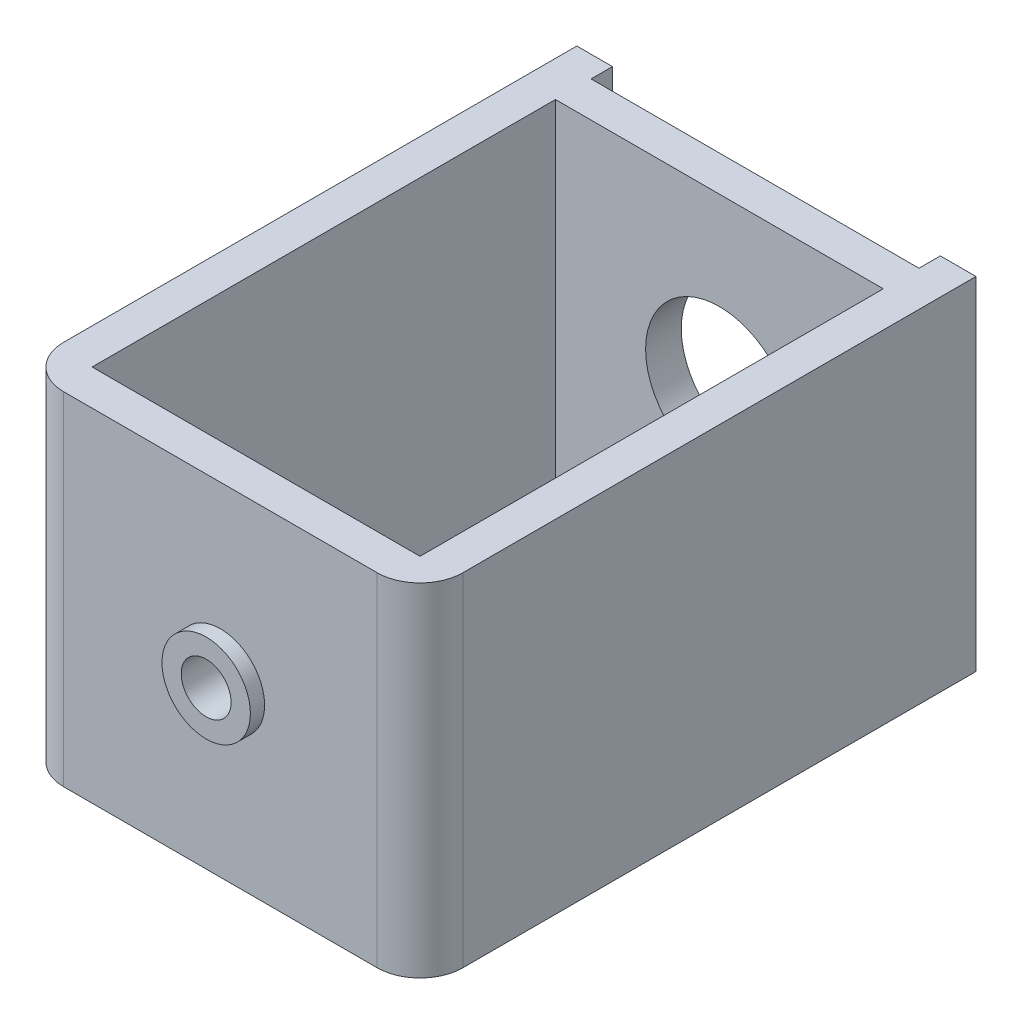
from build123d import *

# Parameters (mm, degrees)
SKETCH1_W           = 28
SKETCH1_H           = 24
BOSS_EXTRUDE1_DEPTH = 39
SKETCH2_W           = 23
SKETCH2_H           = 32.5
SKETCH2_H_2         = 1.5
CUT_EXTRUDE1_DEPTH  = 25
CUT_EXTRUDE2_REACH  = 41
SKETCH3_R           = 5.175
CUT_EXTRUDE3_REACH  = 41
SKETCH4_R           = 1.75
FILLET1_R           = 3
SKETCH5_R           = 3.1
SKETCH5_R_2         = 1.75
BOSS_EXTRUDE2_DEPTH = 1


with BuildPart() as part:
    # Sketch1 → Boss-Extrude1 (new body)
    with BuildSketch(Plane.XY):
        with Locations((14, 12)):
            Rectangle(SKETCH1_W, SKETCH1_H)
    extrude(amount=BOSS_EXTRUDE1_DEPTH)

    # Sketch2 → Cut-Extrude1 (cut, through all)
    with BuildSketch(Plane(origin=(0, 24, 0), x_dir=(1, 0, 0), z_dir=(0, 1, 0))):
        with Locations((14, -20.25)):
            Rectangle(SKETCH2_W, SKETCH2_H)
        with Locations((14, -0.75)):
            Rectangle(SKETCH2_W, SKETCH2_H_2)
    extrude(amount=-CUT_EXTRUDE1_DEPTH, mode=Mode.SUBTRACT)

    # Sketch3 → Cut-Extrude2 (cut, up to next)
    with BuildSketch(Plane(origin=(0, 0, 0), x_dir=(-1, 0, 0), z_dir=(0, 0, -1)), mode=Mode.PRIVATE) as cut_extrude2_sk1:
        with Locations((-14, 12)):
            Circle(SKETCH3_R)
    cut_extrude2_tool1 = extrude(cut_extrude2_sk1.sketch, amount=-CUT_EXTRUDE2_REACH, mode=Mode.PRIVATE) & part.part
    add(cut_extrude2_tool1.solids().sort_by_distance((14, 12, 0))[0], mode=Mode.SUBTRACT)

    # Sketch4 → Cut-Extrude3 (cut, up to next)
    with BuildSketch(Plane.XY.offset(39), mode=Mode.PRIVATE) as cut_extrude3_sk1:
        with Locations((14, 12)):
            Circle(SKETCH4_R)
    cut_extrude3_tool1 = extrude(cut_extrude3_sk1.sketch, amount=-CUT_EXTRUDE3_REACH, mode=Mode.PRIVATE) & part.part
    add(cut_extrude3_tool1.solids().sort_by_distance((14, 12, 39))[0], mode=Mode.SUBTRACT)

    # Fillet1
    fillet1_edges = [part.edges().sort_by_distance(p)[0] for p in [
        (28, 12, 39),
        (0, 12, 39),
    ]]
    fillet(fillet1_edges, radius=FILLET1_R)

    # Sketch5 → Boss-Extrude2 (add)
    with BuildSketch(Plane.XY.offset(39)):
        with Locations((14, 12)):
            Circle(SKETCH5_R)
        with Locations((14, 12)):
            Circle(SKETCH5_R_2, mode=Mode.SUBTRACT)
    extrude(amount=BOSS_EXTRUDE2_DEPTH)


solid = part.part
